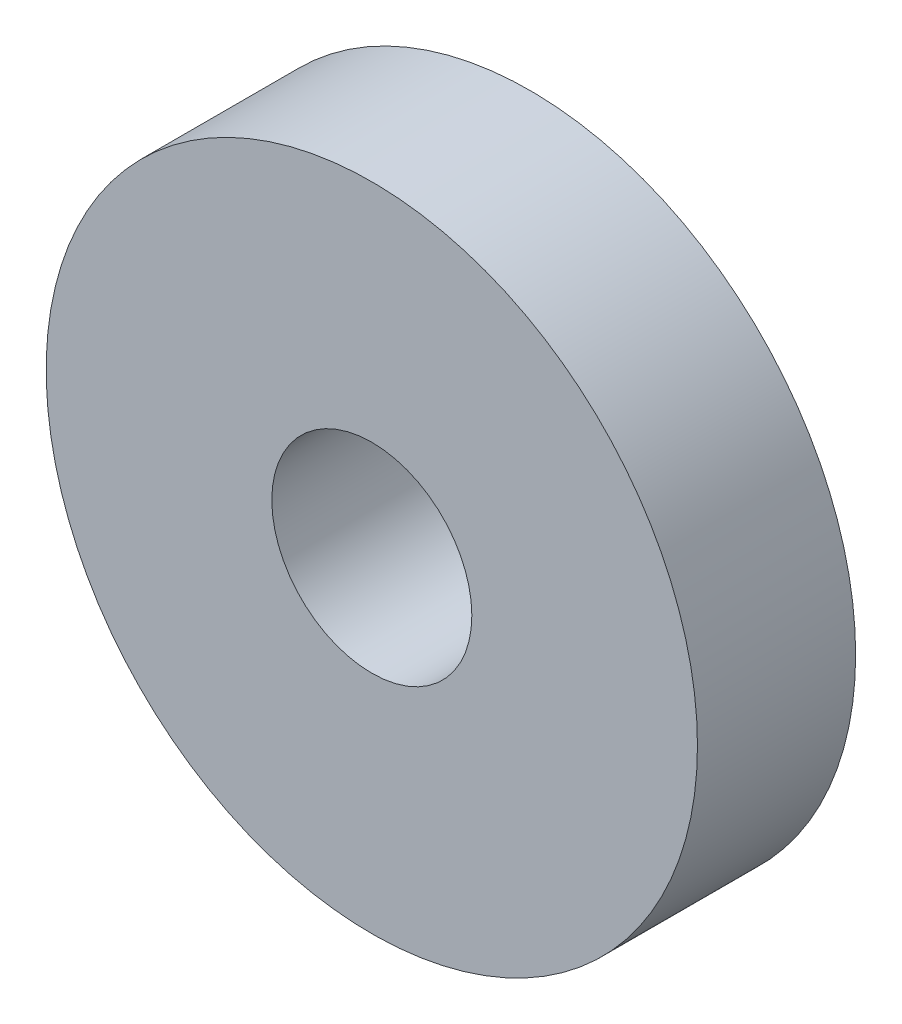
from build123d import *

# Parameters (mm, degrees)
SKETCH1_R           = 7
SKETCH1_R_2         = 2.15
BOSS_EXTRUDE1_DEPTH = 3.4


with BuildPart() as part:
    # Sketch1 → Boss-Extrude1 (new body)
    with BuildSketch(Plane.XY):
        Circle(SKETCH1_R)
        Circle(SKETCH1_R_2, mode=Mode.SUBTRACT)
    extrude(amount=BOSS_EXTRUDE1_DEPTH)


solid = part.part
